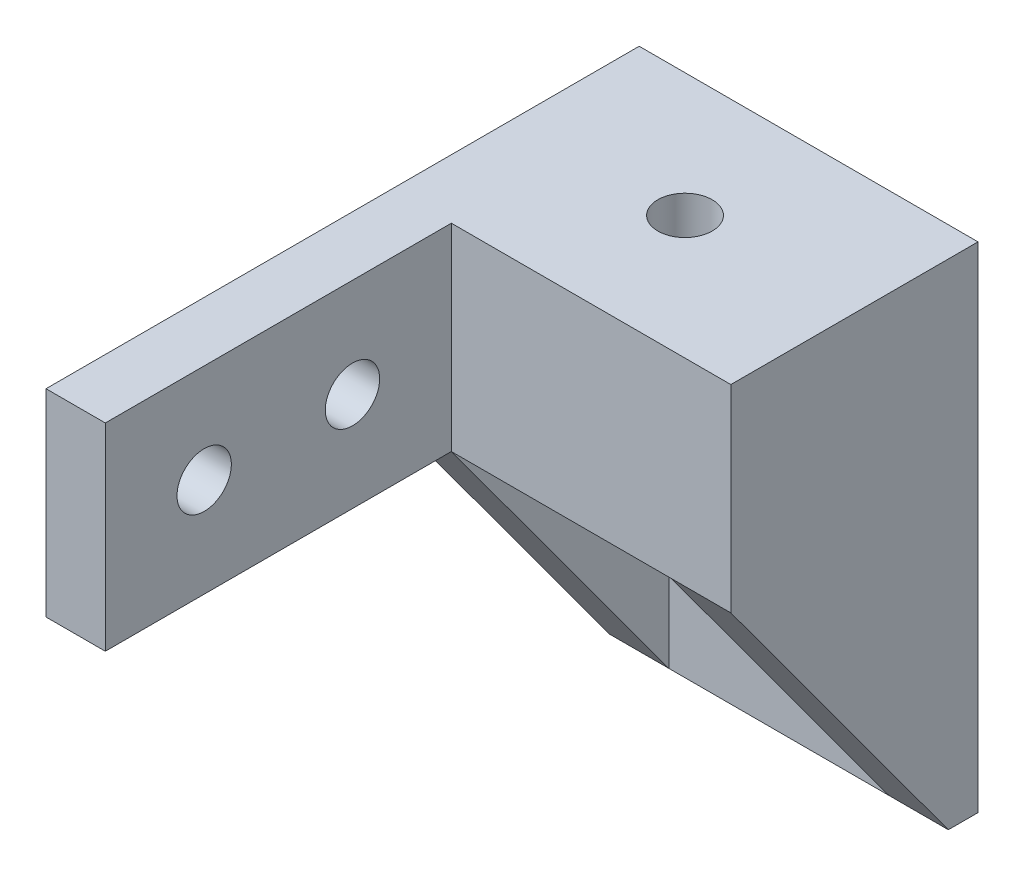
from build123d import *

# Parameters (mm, degrees)
SKETCH1_W           = 17.135
SKETCH1_H           = 12.5
BASE_DEPTH          = 5
SKETCH2_W           = 17.135
SKETCH2_H           = 15
BOSS_EXTRUDE2_DEPTH = 1.5
BOSS_EXTRUDE3_DEPTH = 17.135
SKETCH4_W           = 11.135
SKETCH4_H           = 15
CUT_EXTRUDE1_DEPTH  = 11
SKETCH5_R           = 1.375
CUT_EXTRUDE2_DEPTH  = 2
SKETCH6_R           = 1.375
CUT_EXTRUDE3_DEPTH  = 5.75
SKETCH7_W           = 17.135
SKETCH7_H           = 12.5
SKETCH7_R           = 1.375
BOSS_EXTRUDE4_DEPTH = 5
SKETCH8_W           = 17.5
SKETCH8_H           = 10
SKETCH8_R           = 1.375
BOSS_EXTRUDE5_DEPTH = 3
SKETCH9_W           = 17.5
SKETCH9_H           = 10
CUT_EXTRUDE4_DEPTH  = 10


with BuildPart() as part:
    # Sketch1 → base (new body)
    with BuildSketch(Plane(origin=(0, 0, 0), x_dir=(1, 0, 0), z_dir=(0, 1, 0))):
        with Locations((8.5675, 6.25)):
            Rectangle(SKETCH1_W, SKETCH1_H)
    extrude(amount=BASE_DEPTH)

    # Sketch2 → Boss-Extrude2 (add)
    with BuildSketch(Plane(origin=(0, 0, -12.5), x_dir=(-1, 0, 0), z_dir=(0, 0, -1))):
        with Locations((-8.5675, -7.5)):
            Rectangle(SKETCH2_W, SKETCH2_H)
    extrude(amount=-BOSS_EXTRUDE2_DEPTH)

    # Sketch3 → Boss-Extrude3 (add)
    with BuildSketch(Plane.ZY):
        Polygon((0, 0), (-11, -15), (-11, 0), align=None)
    extrude(amount=-BOSS_EXTRUDE3_DEPTH)

    # Sketch4 → Cut-Extrude1 (cut)
    with BuildSketch(Plane.XY):
        with Locations((8.5675, -7.5)):
            Rectangle(SKETCH4_W, SKETCH4_H)
    extrude(amount=-CUT_EXTRUDE1_DEPTH, mode=Mode.SUBTRACT)

    # Sketch5 → Cut-Extrude2 (cut)
    with BuildSketch(Plane.XY.offset(-11)):
        with Locations((8.5675, -4)):
            Circle(SKETCH5_R)
        with Locations((8.5675, -11)):
            Circle(SKETCH5_R)
    extrude(amount=-CUT_EXTRUDE2_DEPTH, mode=Mode.SUBTRACT)

    # Sketch6 → Cut-Extrude3 (cut)
    with BuildSketch(Plane(origin=(0, 5, 0), x_dir=(1, 0, 0), z_dir=(0, 1, 0))):
        with Locations((8.5675, 6.25)):
            Circle(SKETCH6_R)
    extrude(amount=-CUT_EXTRUDE3_DEPTH, mode=Mode.SUBTRACT)

    # Sketch7 → Boss-Extrude4 (add)
    with BuildSketch(Plane(origin=(0, 5, 0), x_dir=(1, 0, 0), z_dir=(0, 1, 0))):
        with Locations((8.5675, 6.25)):
            Rectangle(SKETCH7_W, SKETCH7_H)
        with Locations((8.5675, 6.25)):
            Circle(SKETCH7_R, mode=Mode.SUBTRACT)
    extrude(amount=BOSS_EXTRUDE4_DEPTH)

    # Sketch8 → Boss-Extrude5 (add)
    with BuildSketch(Plane(origin=(17.135, 0, 0), x_dir=(0, 0, -1), z_dir=(1, 0, 0))):
        with Locations((-8.75, 5)):
            Rectangle(SKETCH8_W, SKETCH8_H)
        with Locations((-5, 5)):
            Circle(SKETCH8_R, mode=Mode.SUBTRACT)
        with Locations((-12.5, 5)):
            Circle(SKETCH8_R, mode=Mode.SUBTRACT)
    boss_extrude5 = extrude(amount=-BOSS_EXTRUDE5_DEPTH)

    # Mirror1: Boss-Extrude5 across plane
    add(boss_extrude5.mirror(Plane.ZY.offset(-8.5675)))

    # Sketch9 → Cut-Extrude4 (cut)
    with BuildSketch(Plane.ZY.offset(-14.135)):
        with Locations((8.75, 5)):
            Rectangle(SKETCH9_W, SKETCH9_H)
    extrude(amount=-CUT_EXTRUDE4_DEPTH, mode=Mode.SUBTRACT)


solid = part.part
